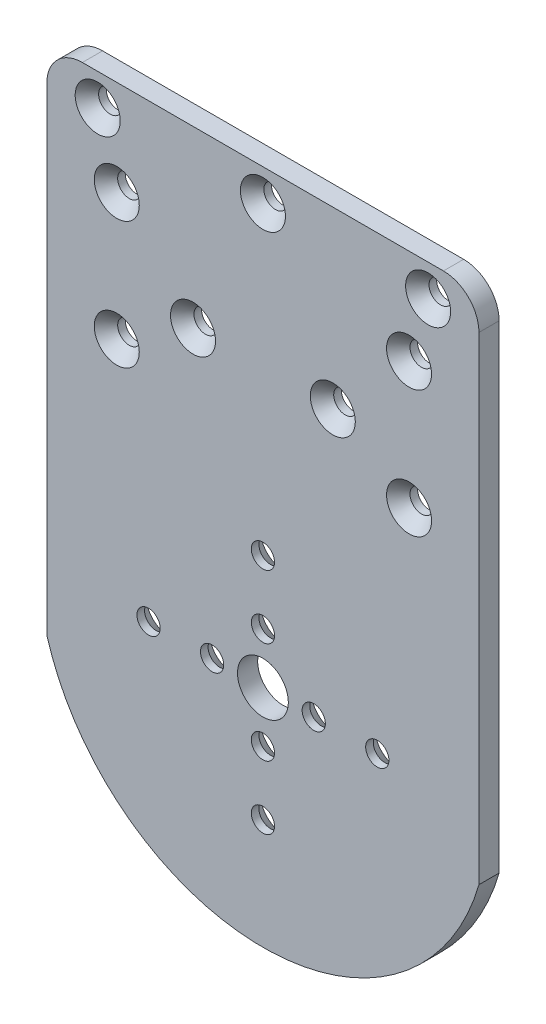
from build123d import *

# Parameters (mm, degrees)
SKETCH1_R                                     = 4
BOSS_EXTRUDE1_DEPTH                           = 3.175
FILLET1_R                                     = 5.588
CSK_FOR_6_FLAT_HEAD_MACHINE_SCREW1_AT_2_COUNT = 2
CSK_FOR_6_FLAT_HEAD_MACHINE_SCREW1_AT_2_PITCH = 16
CSK_FOR_6_FLAT_HEAD_MACHINE_SCREW1_AT_3_COUNT = 2
CSK_FOR_6_FLAT_HEAD_MACHINE_SCREW1_AT_3_PITCH = 11.313708499
CSK_FOR_6_FLAT_HEAD_MACHINE_SCREW1_AT_4_COUNT = 2
CSK_FOR_6_FLAT_HEAD_MACHINE_SCREW1_AT_4_PITCH = 11.313708499
CSK_FOR_6_FLAT_HEAD_MACHINE_SCREW1_AT_5_COUNT = 2
CSK_FOR_6_FLAT_HEAD_MACHINE_SCREW1_AT_5_PITCH = 19.697715604
CSK_FOR_6_FLAT_HEAD_MACHINE_SCREW1_AT_6_COUNT = 2
CSK_FOR_6_FLAT_HEAD_MACHINE_SCREW1_AT_6_PITCH = 26
CSK_FOR_6_FLAT_HEAD_MACHINE_SCREW1_AT_7_COUNT = 2
CSK_FOR_6_FLAT_HEAD_MACHINE_SCREW1_AT_7_PITCH = 19.697715604
CSK_FOR_6_FLAT_HEAD_MACHINE_SCREW1_AT_8_COUNT = 2
CSK_FOR_6_FLAT_HEAD_MACHINE_SCREW1_AT_8_PITCH = 10
CSK_FOR_6_FLAT_HEAD_MACHINE_SCREW2_AT_2_COUNT = 2
CSK_FOR_6_FLAT_HEAD_MACHINE_SCREW2_AT_2_PITCH = 20
CSK_FOR_6_FLAT_HEAD_MACHINE_SCREW2_AT_3_COUNT = 2
CSK_FOR_6_FLAT_HEAD_MACHINE_SCREW2_AT_3_PITCH = 37.802116343
CSK_FOR_6_FLAT_HEAD_MACHINE_SCREW2_AT_4_COUNT = 2
CSK_FOR_6_FLAT_HEAD_MACHINE_SCREW2_AT_4_PITCH = 34.817380717
CSK_FOR_6_FLAT_HEAD_MACHINE_SCREW2_AT_5_COUNT = 2
CSK_FOR_6_FLAT_HEAD_MACHINE_SCREW2_AT_5_PITCH = 46
CSK_FOR_6_FLAT_HEAD_MACHINE_SCREW2_AT_6_COUNT = 2
CSK_FOR_6_FLAT_HEAD_MACHINE_SCREW2_AT_6_PITCH = 50.159744816
CSK_FOR_6_FLAT_HEAD_MACHINE_SCREW2_AT_7_COUNT = 2
CSK_FOR_6_FLAT_HEAD_MACHINE_SCREW2_AT_7_PITCH = 57.454329689
CSK_FOR_6_FLAT_HEAD_MACHINE_SCREW2_AT_8_COUNT = 2
CSK_FOR_6_FLAT_HEAD_MACHINE_SCREW2_AT_8_PITCH = 30.149626863
CSK_FOR_6_FLAT_HEAD_MACHINE_SCREW2_AT_9_COUNT = 2
CSK_FOR_6_FLAT_HEAD_MACHINE_SCREW2_AT_9_PITCH = 14.150971698


with BuildPart() as part:
    # Sketch1 → Boss-Extrude1 (new body)
    with BuildSketch(Plane.XY):
        with BuildLine():
            Line((-34, 71), (-34, -9.856977224))
            ThreePointArc((-34, -9.856977224), (0, -35.4), (34, -9.856977224))
            Line((34, -9.856977224), (34, 71))
            Line((34, 71), (-34, 71))
        make_face()
        Circle(SKETCH1_R, mode=Mode.SUBTRACT)
    extrude(amount=BOSS_EXTRUDE1_DEPTH)

    # Fillet1
    fillet1_edges = [part.edges().sort_by_distance(p)[0] for p in [
        (-34, 71, 1.5875),
        (34, 71, 1.5875),
    ]]
    fillet(fillet1_edges, radius=FILLET1_R)

    # Sketch7 → CSK for _6 Flat Head Machine Screw1 (revolve, cut)
    with BuildSketch(Plane(origin=(0, 8, 0), x_dir=(0, 1, 0), z_dir=(1, 0, 0))):
        Polygon((0, 0), (0, 3.175), (1.8288, 3.175), (1.8288, 1.972306634), (3.5433, 0), align=None)
    csk_for_6_flat_head_machine_screw1 = revolve(axis=Axis((0, 8, -6.35), (0, 0, 1)), mode=Mode.SUBTRACT)

    # CSK for _6 Flat Head Machine Screw1 at 2: CSK for _6 Flat Head Machine Screw1 ×2
    with Locations(*[(0, -i * CSK_FOR_6_FLAT_HEAD_MACHINE_SCREW1_AT_2_PITCH, 0) for i in range(1, CSK_FOR_6_FLAT_HEAD_MACHINE_SCREW1_AT_2_COUNT)]):
        add(csk_for_6_flat_head_machine_screw1, mode=Mode.SUBTRACT)

    # CSK for _6 Flat Head Machine Screw1 at 3: CSK for _6 Flat Head Machine Screw1 ×2
    with Locations(*[Vector(0.7071067811865476, -0.7071067811865476, 0) * (i * CSK_FOR_6_FLAT_HEAD_MACHINE_SCREW1_AT_3_PITCH) for i in range(1, CSK_FOR_6_FLAT_HEAD_MACHINE_SCREW1_AT_3_COUNT)]):
        add(csk_for_6_flat_head_machine_screw1, mode=Mode.SUBTRACT)

    # CSK for _6 Flat Head Machine Screw1 at 4: CSK for _6 Flat Head Machine Screw1 ×2
    with Locations(*[Vector(-0.7071067811865476, -0.7071067811865476, 0) * (i * CSK_FOR_6_FLAT_HEAD_MACHINE_SCREW1_AT_4_PITCH) for i in range(1, CSK_FOR_6_FLAT_HEAD_MACHINE_SCREW1_AT_4_COUNT)]):
        add(csk_for_6_flat_head_machine_screw1, mode=Mode.SUBTRACT)

    # CSK for _6 Flat Head Machine Screw1 at 5: CSK for _6 Flat Head Machine Screw1 ×2
    with Locations(*[Vector(0.9138115486202574, -0.40613846605344706, 0) * (i * CSK_FOR_6_FLAT_HEAD_MACHINE_SCREW1_AT_5_PITCH) for i in range(1, CSK_FOR_6_FLAT_HEAD_MACHINE_SCREW1_AT_5_COUNT)]):
        add(csk_for_6_flat_head_machine_screw1, mode=Mode.SUBTRACT)

    # CSK for _6 Flat Head Machine Screw1 at 6: CSK for _6 Flat Head Machine Screw1 ×2
    with Locations(*[(0, -i * CSK_FOR_6_FLAT_HEAD_MACHINE_SCREW1_AT_6_PITCH, 0) for i in range(1, CSK_FOR_6_FLAT_HEAD_MACHINE_SCREW1_AT_6_COUNT)]):
        add(csk_for_6_flat_head_machine_screw1, mode=Mode.SUBTRACT)

    # CSK for _6 Flat Head Machine Screw1 at 7: CSK for _6 Flat Head Machine Screw1 ×2
    with Locations(*[Vector(-0.9138115486202574, -0.40613846605344706, 0) * (i * CSK_FOR_6_FLAT_HEAD_MACHINE_SCREW1_AT_7_PITCH) for i in range(1, CSK_FOR_6_FLAT_HEAD_MACHINE_SCREW1_AT_7_COUNT)]):
        add(csk_for_6_flat_head_machine_screw1, mode=Mode.SUBTRACT)

    # CSK for _6 Flat Head Machine Screw1 at 8: CSK for _6 Flat Head Machine Screw1 ×2
    with Locations(*[(0, i * CSK_FOR_6_FLAT_HEAD_MACHINE_SCREW1_AT_8_PITCH, 0) for i in range(1, CSK_FOR_6_FLAT_HEAD_MACHINE_SCREW1_AT_8_COUNT)]):
        add(csk_for_6_flat_head_machine_screw1, mode=Mode.SUBTRACT)

    # Sketch9 → CSK for _6 Flat Head Machine Screw2 (revolve, cut)
    with BuildSketch(Plane(origin=(23, 36, 3.175), x_dir=(0, -1, 0), z_dir=(1, 0, 0))):
        Polygon((0, 0), (0, 3.175), (1.8288, 3.175), (1.8288, 1.972306634), (3.5433, 0), align=None)
    csk_for_6_flat_head_machine_screw2 = revolve(axis=Axis((23, 36, 9.525), (0, 0, -1)), mode=Mode.SUBTRACT)

    # CSK for _6 Flat Head Machine Screw2 at 2: CSK for _6 Flat Head Machine Screw2 ×2
    with Locations(*[(0, i * CSK_FOR_6_FLAT_HEAD_MACHINE_SCREW2_AT_2_PITCH, 0) for i in range(1, CSK_FOR_6_FLAT_HEAD_MACHINE_SCREW2_AT_2_COUNT)]):
        add(csk_for_6_flat_head_machine_screw2, mode=Mode.SUBTRACT)

    # CSK for _6 Flat Head Machine Screw2 at 3: CSK for _6 Flat Head Machine Screw2 ×2
    with Locations(*[Vector(-0.6084315436571349, 0.7936063612919166, 0) * (i * CSK_FOR_6_FLAT_HEAD_MACHINE_SCREW2_AT_3_PITCH) for i in range(1, CSK_FOR_6_FLAT_HEAD_MACHINE_SCREW2_AT_3_COUNT)]):
        add(csk_for_6_flat_head_machine_screw2, mode=Mode.SUBTRACT)

    # CSK for _6 Flat Head Machine Screw2 at 4: CSK for _6 Flat Head Machine Screw2 ×2
    with Locations(*[Vector(-0.9765237734639312, 0.21540965591116132, 0) * (i * CSK_FOR_6_FLAT_HEAD_MACHINE_SCREW2_AT_4_PITCH) for i in range(1, CSK_FOR_6_FLAT_HEAD_MACHINE_SCREW2_AT_4_COUNT)]):
        add(csk_for_6_flat_head_machine_screw2, mode=Mode.SUBTRACT)

    # CSK for _6 Flat Head Machine Screw2 at 5: CSK for _6 Flat Head Machine Screw2 ×2
    with Locations(*[(-i * CSK_FOR_6_FLAT_HEAD_MACHINE_SCREW2_AT_5_PITCH, 0, 0) for i in range(1, CSK_FOR_6_FLAT_HEAD_MACHINE_SCREW2_AT_5_COUNT)]):
        add(csk_for_6_flat_head_machine_screw2, mode=Mode.SUBTRACT)

    # CSK for _6 Flat Head Machine Screw2 at 6: CSK for _6 Flat Head Machine Screw2 ×2
    with Locations(*[Vector(-0.9170700562532351, 0.3987261114144499, 0) * (i * CSK_FOR_6_FLAT_HEAD_MACHINE_SCREW2_AT_6_PITCH) for i in range(1, CSK_FOR_6_FLAT_HEAD_MACHINE_SCREW2_AT_6_COUNT)]):
        add(csk_for_6_flat_head_machine_screw2, mode=Mode.SUBTRACT)

    # CSK for _6 Flat Head Machine Screw2 at 7: CSK for _6 Flat Head Machine Screw2 ×2
    with Locations(*[Vector(-0.8528513040762653, 0.52215385963853, 0) * (i * CSK_FOR_6_FLAT_HEAD_MACHINE_SCREW2_AT_7_PITCH) for i in range(1, CSK_FOR_6_FLAT_HEAD_MACHINE_SCREW2_AT_7_COUNT)]):
        add(csk_for_6_flat_head_machine_screw2, mode=Mode.SUBTRACT)

    # CSK for _6 Flat Head Machine Screw2 at 8: CSK for _6 Flat Head Machine Screw2 ×2
    with Locations(*[Vector(0.09950371902099815, 0.9950371902099893, 0) * (i * CSK_FOR_6_FLAT_HEAD_MACHINE_SCREW2_AT_8_PITCH) for i in range(1, CSK_FOR_6_FLAT_HEAD_MACHINE_SCREW2_AT_8_COUNT)]):
        add(csk_for_6_flat_head_machine_screw2, mode=Mode.SUBTRACT)

    # CSK for _6 Flat Head Machine Screw2 at 9: CSK for _6 Flat Head Machine Screw2 ×2
    with Locations(*[Vector(-0.8479983040050879, 0.5299989400031803, 0) * (i * CSK_FOR_6_FLAT_HEAD_MACHINE_SCREW2_AT_9_PITCH) for i in range(1, CSK_FOR_6_FLAT_HEAD_MACHINE_SCREW2_AT_9_COUNT)]):
        add(csk_for_6_flat_head_machine_screw2, mode=Mode.SUBTRACT)


solid = part.part
